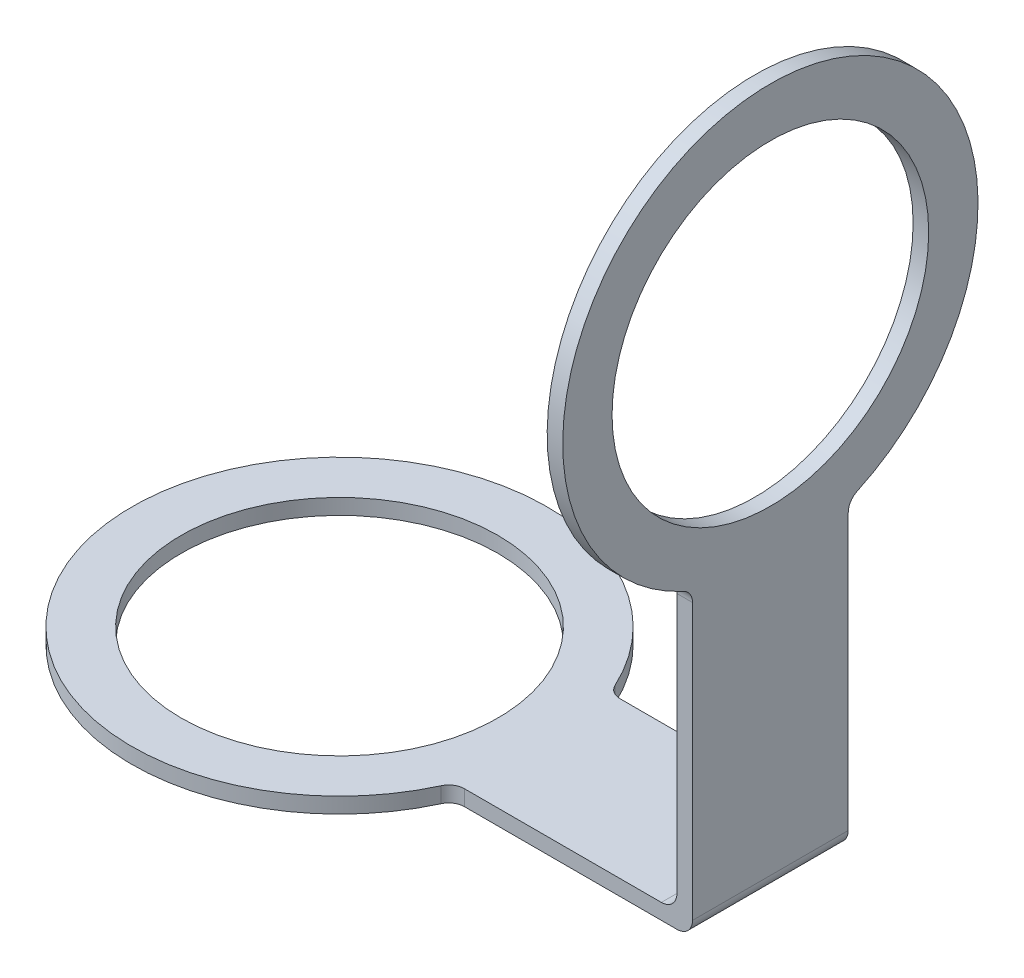
from build123d import *

# Parameters (mm, degrees)
SKETCH1_R           = 40
SKETCH1_R_2         = 30.5
BOSS_EXTRUDE1_DEPTH = 3
SKETCH2_W           = 48
SKETCH2_H           = 30
BOSS_EXTRUDE2_DEPTH = 3
SKETCH3_R           = 30.5
BOSS_EXTRUDE3_DEPTH = 3
FILLET1_R           = 3
FILLET2_R           = 3


with BuildPart() as part:
    # Sketch1 → Boss-Extrude1 (new body)
    with BuildSketch(Plane(origin=(0, 0, 0), x_dir=(1, 0, 0), z_dir=(0, 1, 0))):
        Circle(SKETCH1_R)
        Circle(SKETCH1_R_2, mode=Mode.SUBTRACT)
    extrude(amount=BOSS_EXTRUDE1_DEPTH)

    # Sketch2 → Boss-Extrude2 (add)
    with BuildSketch(Plane(origin=(0, 3, 0), x_dir=(1, 0, 0), z_dir=(0, 1, 0))):
        with Locations((59, 0)):
            Rectangle(SKETCH2_W, SKETCH2_H)
    extrude(amount=-BOSS_EXTRUDE2_DEPTH)

    # Sketch3 → Boss-Extrude3 (add)
    with BuildSketch(Plane(origin=(83, 0, 0), x_dir=(0, 0, -1), z_dir=(1, 0, 0))):
        with BuildLine():
            Line((-15, 0), (15, 0))
            Line((15, 0), (15, 58))
            ThreePointArc((15, 58), (0, 135.080992435), (-15, 58))
            Line((-15, 58), (-15, 0))
        make_face()
        with Locations((0, 95.080992435)):
            Circle(SKETCH3_R, mode=Mode.SUBTRACT)
    extrude(amount=-BOSS_EXTRUDE3_DEPTH)

    # Fillet1
    fillet1_edges = [part.edges().sort_by_distance(p)[0] for p in [
        (37.080992435, 1.5, 15),
        (37.080992435, 1.5, -15),
        (81.5, 58, 15),
        (81.5, 58, -15),
    ]]
    fillet(fillet1_edges, radius=FILLET1_R)

    # Fillet2
    fillet2_edges = [part.edges().sort_by_distance(p)[0] for p in [
        (83, 0, 0),
        (80, 3, 0),
    ]]
    fillet(fillet2_edges, radius=FILLET2_R)


solid = part.part
